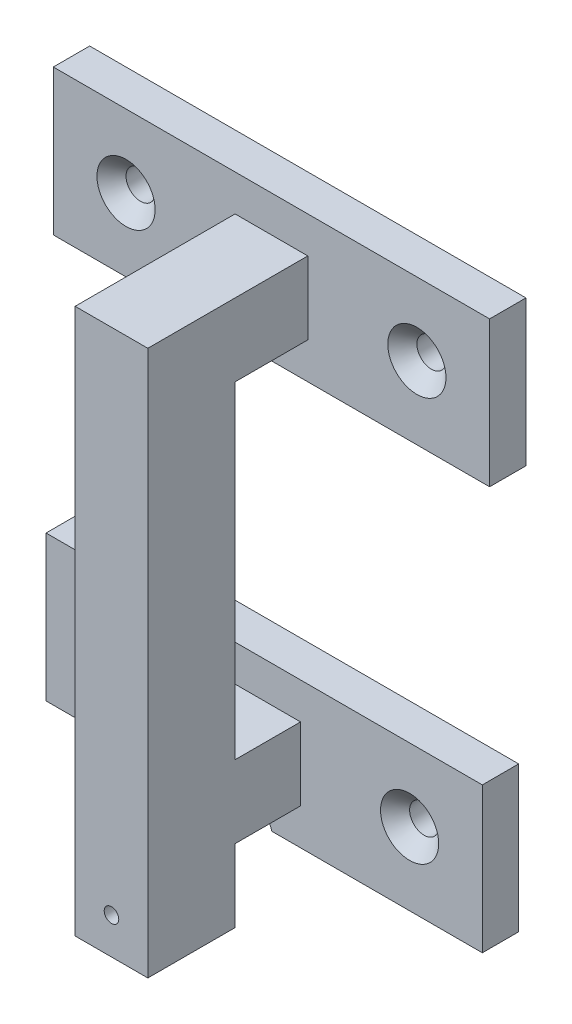
from build123d import *

# Parameters (mm, degrees)
SKETCH1_W                = 10
SKETCH1_H                = 10
BOSS_EXTRUDE1_DEPTH      = 5
SKETCH2_W                = 10
SKETCH2_H                = 10
BOSS_EXTRUDE2_DEPTH      = 20
SKETCH3_W                = 60
SKETCH3_H                = 20
SKETCH3_R                = 2
BOSS_EXTRUDE3_DEPTH      = 5
SKETCH4_W                = 10
SKETCH4_H                = 12
BOSS_EXTRUDE4_DEPTH      = 10
BOSS_EXTRUDE4_DEPTH_BACK = 65
SKETCH5_W                = 4.1
SKETCH5_H                = 3.1
SKETCH5_W_2              = 1.6
SKETCH5_H_2              = 2.1
CUT_EXTRUDE1_DEPTH       = 13
SKETCH7_R                = 1
CUT_EXTRUDE3_DEPTH       = 27
SKETCH10_W               = 10
SKETCH10_H               = 10
BOSS_EXTRUDE6_DEPTH      = 10
SKETCH12_W               = 60
SKETCH12_H               = 20
SKETCH12_R               = 2
BOSS_EXTRUDE7_DEPTH      = 5
CHAMFER1_SIZE            = 2


with BuildPart() as part:
    # Sketch1 → Boss-Extrude1 (new body)
    with BuildSketch(Plane.XY):
        Rectangle(SKETCH1_W, SKETCH1_H)
    extrude(amount=BOSS_EXTRUDE1_DEPTH)

    # Sketch2 → Boss-Extrude2 (add)
    with BuildSketch(Plane(origin=(0, 0, 0), x_dir=(-1, 0, 0), z_dir=(0, 0, -1))):
        Rectangle(SKETCH2_W, SKETCH2_H)
    extrude(amount=BOSS_EXTRUDE2_DEPTH)

    # Sketch3 → Boss-Extrude3 (add)
    with BuildSketch(Plane(origin=(0, 0, -20), x_dir=(-1, 0, 0), z_dir=(0, 0, -1))):
        Rectangle(SKETCH3_W, SKETCH3_H)
        with Locations((20, 0)):
            Circle(SKETCH3_R, mode=Mode.SUBTRACT)
        with Locations((-20, 0)):
            Circle(SKETCH3_R, mode=Mode.SUBTRACT)
    extrude(amount=-BOSS_EXTRUDE3_DEPTH)

    # Sketch4 → Boss-Extrude4 (add, two sides)
    with BuildSketch(Plane.XZ.offset(5)) as boss_extrude4_sk:
        Rectangle(SKETCH4_W, SKETCH4_H)
    extrude(amount=BOSS_EXTRUDE4_DEPTH)
    extrude(boss_extrude4_sk.sketch, amount=-BOSS_EXTRUDE4_DEPTH_BACK)

    # Sketch5 → Cut-Extrude1 (cut)
    with BuildSketch(Plane(origin=(0, -15, 0), x_dir=(-1, 0, 0), z_dir=(0, -1, 0))):
        Rectangle(SKETCH5_W, SKETCH5_H)
        with Locations((-2.85, 0)):
            Rectangle(SKETCH5_W_2, SKETCH5_H_2)
    extrude(amount=-CUT_EXTRUDE1_DEPTH, mode=Mode.SUBTRACT)

    # Sketch7 → Cut-Extrude3 (cut, through all)
    with BuildSketch(Plane.XY.offset(6)):
        with Locations((0, -10)):
            Circle(SKETCH7_R)
    extrude(amount=-CUT_EXTRUDE3_DEPTH, mode=Mode.SUBTRACT)

    # Sketch10 → Boss-Extrude6 (add)
    with BuildSketch(Plane(origin=(0, 0, -6), x_dir=(-1, 0, 0), z_dir=(0, 0, -1))):
        with Locations((0, 55)):
            Rectangle(SKETCH10_W, SKETCH10_H)
    extrude(amount=BOSS_EXTRUDE6_DEPTH)

    # Sketch12 → Boss-Extrude7 (add)
    with BuildSketch(Plane(origin=(0, 0, -16), x_dir=(-1, 0, 0), z_dir=(0, 0, -1))):
        with Locations((0, 55)):
            Rectangle(SKETCH12_W, SKETCH12_H)
        with Locations((20, 55)):
            Circle(SKETCH12_R, mode=Mode.SUBTRACT)
        with Locations((-20, 55)):
            Circle(SKETCH12_R, mode=Mode.SUBTRACT)
    extrude(amount=BOSS_EXTRUDE7_DEPTH)

    # Chamfer1
    chamfer1_edges = [part.edges().sort_by_distance(p)[0] for p in [
        (-18, 55, -16),
        (22, 55, -16),
        (-18, 0, -15),
        (22, 0, -15),
    ]]
    chamfer(chamfer1_edges, length=CHAMFER1_SIZE)


solid = part.part
